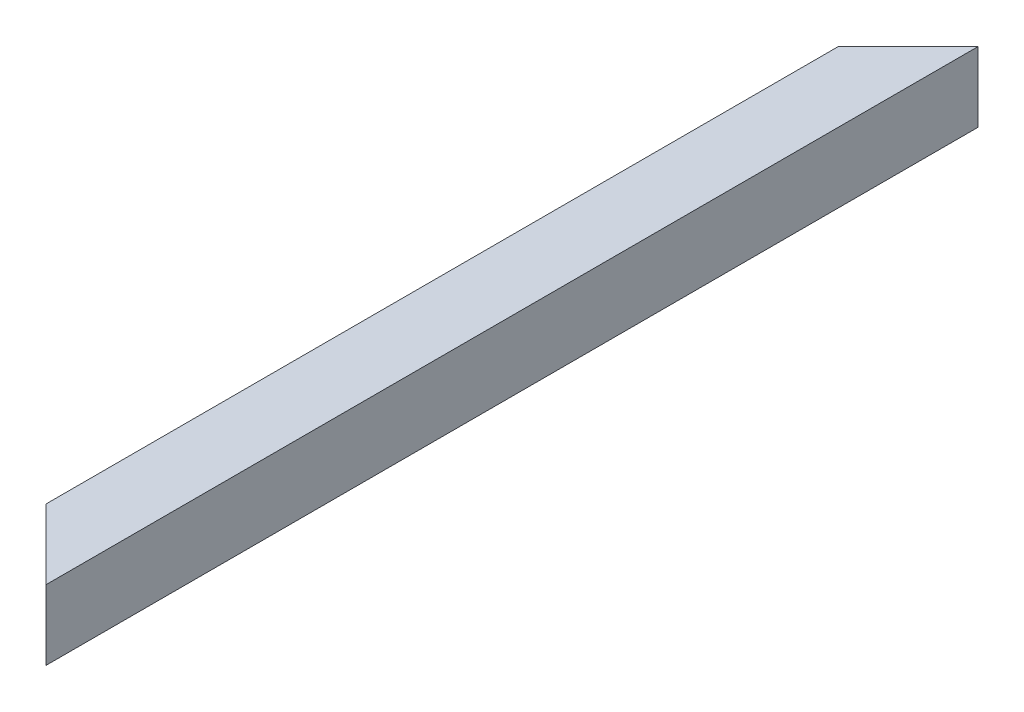
from build123d import *

# Parameters (mm, degrees)
SKETCH1_W          = 60
SKETCH1_H          = 60
SKETCH1_W_2        = 52
SKETCH1_H_2        = 52
CUT_EXTRUDE1_DEPTH = 61.0000001


with BuildPart() as part:
    # Sweep1: sweep along a curve in space
    with BuildLine() as sweep1_path:
        add(Edge.make_bspline(
            [(0, 0, 0), (0, 0, 800)],
            knots=[0, 0, 1, 1], degree=1))
    # Sketch1 → Sweep1 (sweep)
    with BuildSketch(Plane.XY):
        Rectangle(SKETCH1_W, SKETCH1_H)
        Rectangle(SKETCH1_W_2, SKETCH1_H_2, mode=Mode.SUBTRACT)
    sweep(path=sweep1_path.line)

    # Sketch2 → Cut-Extrude1 (cut, through all)
    with BuildSketch(Plane(origin=(0, 30, 0), x_dir=(1, 0, 0), z_dir=(0, 1, 0))):
        Polygon((30, 0), (-30, -60), (-30, 0), align=None)
        Polygon((30, -800), (-30, -740), (-30, -800), align=None)
    extrude(amount=-CUT_EXTRUDE1_DEPTH, mode=Mode.SUBTRACT)


solid = part.part
